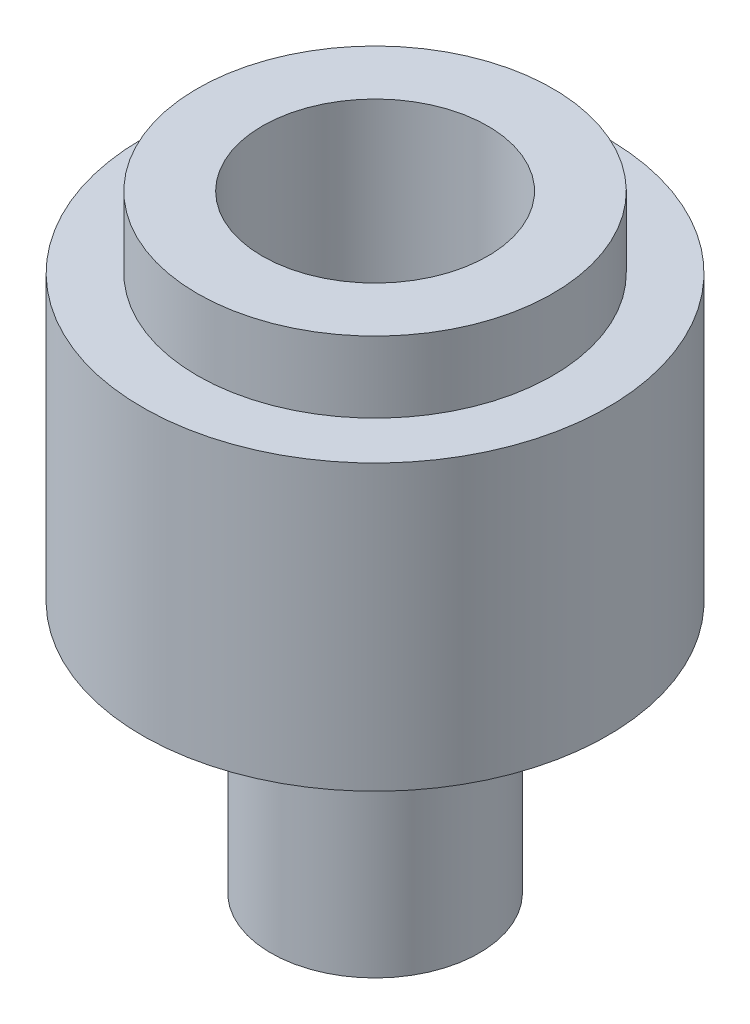
from build123d import *

# Parameters (mm, degrees)
SKETCH3_R           = 3.75
SKETCH3_R_2         = 2.38
BOSS_EXTRUDE1_DEPTH = 1.5


with BuildPart() as part:
    # Sketch1 → Revolve1 (revolve)
    with BuildSketch(Plane.XY):
        Polygon((2.2, 1.270170592), (0, 0), (0, 6.646746758), (2.38, 8.076795031), (2.38, 12.6), (4.91, 12.6), (4.91, 6.6), (2.2, 5.03538077), align=None)
    revolve(axis=Axis((0, 6.646746758, 0), (0, -1, 0)))

    # Sketch3 → Boss-Extrude1 (add)
    with BuildSketch(Plane(origin=(0, 12.6, 0), x_dir=(1, 0, 0), z_dir=(0, 1, 0))):
        Circle(SKETCH3_R)
        Circle(SKETCH3_R_2, mode=Mode.SUBTRACT)
    extrude(amount=BOSS_EXTRUDE1_DEPTH)


solid = part.part
